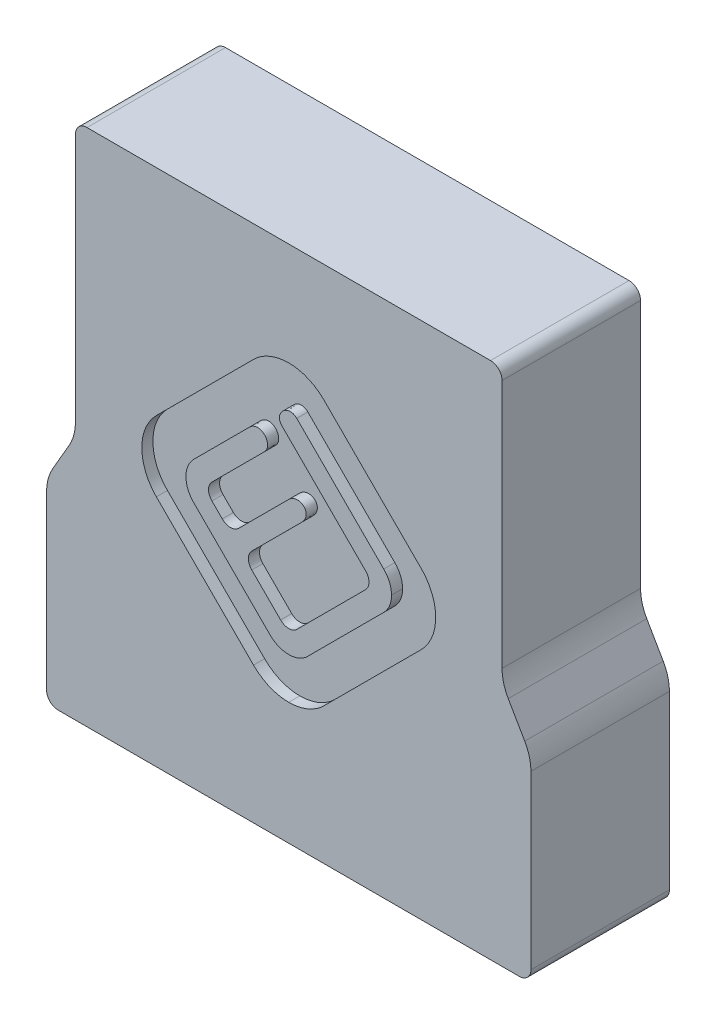
from build123d import *

# Parameters (mm, degrees)
OVERLAP_PROFILE_DEPTH              = 5.08
END_THICKNESS_DEPTH                = 13.97
FILLET1_R                          = 1.5875
FILLET2_R                          = 1.5875
SKETCH7_W                          = 28.6385
SKETCH7_H                          = 5.588
BOTTOM_FILL_DEPTH                  = 19.05
LOGO_INLAY_CUTOUT_DEPTH            = 1.524
SIDE_TRANSITION_FILL_DEPTH         = 19.05
SKETCH8_W                          = 52.324
SKETCH8_H                          = 20.828
MAGNETIC_CATCH_CUTOUT_DEPTH        = 7.62
FILLET3_R                          = 6.35
FILLET4_R                          = 6.35
SKETCH10_R                         = 3.175
ROUTER_BIT_RELIEF_DEPTH            = 7.62
FILLET5_R                          = 3.175
LOGO_FILL_FOR_1_8_ROUTER_BIT_DEPTH = 1.524


with BuildPart() as part:
    # Sketch1 → Overlap Profile (new body)
    with BuildSketch(Plane.XY):
        Polygon((-14.31925, -36.449), (14.31925, -36.449), (14.31925, -42.037), (33.30575, -42.037), (33.30575, -15.113), (29.337, -15.113), (29.337, 29.337), (-29.337, 29.337), (-29.337, -15.113), (-33.30575, -15.113), (-33.30575, -42.037), (-14.31925, -42.037), align=None)
        Polygon((-17.49425, -33.274), (17.49425, -33.274), (17.49425, -38.862), (30.13075, -38.862), (30.13075, -18.288), (26.162, -18.288), (26.162, 26.162), (-26.162, 26.162), (-26.162, -18.288), (-30.13075, -18.288), (-30.13075, -38.862), (-17.49425, -38.862), align=None, mode=Mode.SUBTRACT)
    extrude(amount=-OVERLAP_PROFILE_DEPTH)

    # Sketch2 → End Thickness (add)
    with BuildSketch(Plane.XY):
        Polygon((-29.337, 29.337), (-29.337, -15.113), (-33.30575, -15.113), (-33.30575, -42.037), (-14.31925, -42.037), (-14.31925, -36.449), (14.31925, -36.449), (14.31925, -42.037), (33.30575, -42.037), (33.30575, -15.113), (29.337, -15.113), (29.337, 29.337), align=None)
    extrude(amount=END_THICKNESS_DEPTH)

    # Fillet1
    fillet1_edges = [part.edges().sort_by_distance(p)[0] for p in [
        (17.49425, -38.862, -2.54),
        (17.49425, -33.274, -2.54),
        (-17.49425, -33.274, -2.54),
        (-17.49425, -38.862, -2.54),
        (-30.13075, -38.862, -2.54),
        (-30.13075, -18.288, -2.54),
        (-26.162, -18.288, -2.54),
        (-26.162, 26.162, -2.54),
        (26.162, 26.162, -2.54),
        (26.162, -18.288, -2.54),
        (30.13075, -18.288, -2.54),
        (30.13075, -38.862, -2.54),
    ]]
    fillet(fillet1_edges, radius=FILLET1_R)

    # Fillet2
    fillet2_edges = [part.edges().sort_by_distance(p)[0] for p in [
        (-33.30575, -42.037, 4.445),
        (-29.337, 29.337, 4.445),
        (29.337, 29.337, 4.445),
        (33.30575, -42.037, 4.445),
    ]]
    fillet(fillet2_edges, radius=FILLET2_R)

    # Sketch7 → Bottom Fill (add)
    with BuildSketch(Plane(origin=(0, 0, -5.08), x_dir=(-1, 0, 0), z_dir=(0, 0, -1))):
        with Locations((0, -39.243)):
            Rectangle(SKETCH7_W, SKETCH7_H)
    extrude(amount=-BOTTOM_FILL_DEPTH)

    # Sketch5 → Logo Inlay Cutout (cut)
    with BuildSketch(Plane.XY.offset(13.97)):
        with BuildLine():
            Line((18.205177148, -0.187852502), (4.843750234, 13.173642935))
            add(Edge.make_bspline(
                [(4.843750234, 13.173642935), (3.54948877, 14.467561785), (1.829288652, 15.180131934), (0, 15.180131934)],
                knots=[1, 1, 1, 1, 2, 2, 2, 2], degree=3))
            add(Edge.make_bspline(
                [(0, 15.180131934), (-1.829494221, 15.180131934), (-3.549865646, 14.467561785), (-4.843167789, 13.173642935)],
                knots=[2, 2, 2, 2, 3, 3, 3, 3], degree=3))
            Line((-4.843167789, 13.173642935), (-18.205279933, -0.187852502))
            add(Edge.make_bspline(
                [(-18.205279933, -0.187852502), (-20.875413695, -2.858740017), (-20.875413695, -7.203951534), (-18.204868795, -9.874907572)],
                knots=[4, 4, 4, 4, 5, 5, 5, 5], degree=3))
            Line((-18.204868795, -9.874907572), (-4.843167789, -23.236471532))
            add(Edge.make_bspline(
                [(-4.843167789, -23.236471532), (-3.549865646, -24.530321859), (-1.829494221, -25.242892008), (0, -25.242892008)],
                knots=[6, 6, 6, 6, 7, 7, 7, 7], degree=3))
            add(Edge.make_bspline(
                [(0, -25.242892008), (1.829288652, -25.242892008), (3.54948877, -24.530321859), (4.843750234, -23.236471532)],
                knots=[7, 7, 7, 7, 8, 8, 8, 8], degree=3))
            Line((4.843750234, -23.236471532), (18.205177148, -9.874907572))
            add(Edge.make_bspline(
                [(18.205177148, -9.874907572), (20.876475801, -7.203951534), (20.876475801, -2.858740017), (18.205177148, -0.187852502)],
                knots=[9, 9, 9, 9, 10, 10, 10, 10], degree=3))
        make_face()
        with BuildLine():
            Line((13.064585498, -8.006012655), (2.584548599, -18.487145921))
            add(Edge.make_bspline(
                [(2.584548599, -18.487145921), (1.895207729, -19.177583158), (0.977274302, -19.558570755), (0, -19.557474388)],
                knots=[1, 1, 1, 1, 2, 2, 2, 2], degree=3))
            add(Edge.make_bspline(
                [(0, -19.557474388), (-0.976691857, -19.557474388), (-1.893254825, -19.177583158), (-2.584411553, -18.485501371)],
                knots=[2, 2, 2, 2, 3, 3, 3, 3], degree=3))
            Line((-2.584411553, -18.485501371), (-13.06461976, -8.006012655))
            add(Edge.make_bspline(
                [(-13.06461976, -8.006012655), (-13.756016317, -7.315986556), (-14.136010332, -6.398601312), (-14.136010332, -5.421738148)],
                knots=[4, 4, 4, 4, 5, 5, 5, 5], degree=3))
            add(Edge.make_bspline(
                [(-14.136010332, -5.421738148), (-14.136010332, -4.444737938), (-13.755570918, -3.527798093), (-13.06461976, -2.837292334)],
                knots=[5, 5, 5, 5, 6, 6, 6, 6], degree=3))
            add(Edge.make_bspline(
                [(-13.06461976, -2.837292334), (-8.199798718, 2.027700015), (-5.428662129, 4.798768081)],
                knots=[6, 6, 6, 7, 7, 7], degree=2))
            add(Edge.make_bspline(
                [(-5.428662129, 4.798768081), (-3.839306583, 6.387198567), (-2.073024783, 4.195971697), (-3.333264603, 2.936382845)],
                knots=[7, 7, 7, 7, 8, 8, 8, 8], degree=3))
            add(Edge.make_bspline(
                [(-3.333264603, 2.936382845), (-6.104161362, 0.163773012), (-11.086122385, -4.81630363)],
                knots=[8, 8, 8, 9, 9, 9], degree=2))
            add(Edge.make_bspline(
                [(-11.086122385, -4.81630363), (-11.247288362, -4.978428928), (-11.336745072, -5.192871498), (-11.336745072, -5.421738148)],
                knots=[9, 9, 9, 9, 10, 10, 10, 10], degree=3))
            add(Edge.make_bspline(
                [(-11.336745072, -5.421738148), (-11.336059843, -5.650056615), (-11.247288362, -5.865150152), (-11.084991757, -6.026932835)],
                knots=[10, 10, 10, 10, 11, 11, 11, 11], degree=3))
            Line((-11.084991757, -6.026932835), (-8.017356366, -9.096898006))
            add(Edge.make_bspline(
                [(-8.017356366, -9.096898006), (-1.827952455, -2.908933077), (-0.025250707, -1.106128545)],
                knots=[12, 12, 12, 13, 13, 13], degree=2))
            add(Edge.make_bspline(
                [(-0.025250707, -1.106128545), (1.428977583, 0.347551562), (3.4298477, -1.263697066), (1.800783105, -2.893549675)],
                knots=[13, 13, 13, 13, 14, 14, 14, 14], degree=3))
            add(Edge.make_bspline(
                [(1.800783105, -2.893549675), (0.095383945, -4.599394234), (-6.209412612, -10.903299994)],
                knots=[14, 14, 14, 15, 15, 15], degree=2))
            Line((-6.209412612, -10.903299994), (-0.605503041, -16.507449395))
            add(Edge.make_bspline(
                [(-0.605503041, -16.507449395), (-0.443686096, -16.669095033), (-0.228352728, -16.758380436), (0, -16.758380436)],
                knots=[16, 16, 16, 16, 17, 17, 17, 17], degree=3))
            add(Edge.make_bspline(
                [(0, -16.758380436), (0.22955188, -16.758380436), (0.443754619, -16.669780262), (0.606016963, -16.50779201)],
                knots=[17, 17, 17, 17, 18, 18, 18, 18], degree=3))
            Line((0.606016963, -16.50779201), (11.086465, -6.027206927))
            add(Edge.make_bspline(
                [(11.086465, -6.027206927), (11.247630977, -5.865150152), (11.336436719, -5.649371385), (11.336847856, -5.422560423)],
                knots=[19, 19, 19, 19, 20, 20, 20, 20], degree=3))
            add(Edge.make_bspline(
                [(11.336847856, -5.422560423), (11.336847856, -5.192871498), (11.247630977, -4.977675175), (11.085779771, -4.81630363)],
                knots=[20, 20, 20, 20, 21, 21, 21, 21], degree=3))
            add(Edge.make_bspline(
                [(11.085779771, -4.81630363), (2.592908398, 3.67581399), (-0.913993358, 7.184051944)],
                knots=[21, 21, 21, 22, 22, 22], degree=2))
            add(Edge.make_bspline(
                [(-0.913993358, 7.184051944), (-2.11687947, 8.385807427), (-0.0785273, 10.307533538), (1.103356528, 9.124621866)],
                knots=[22, 22, 22, 22, 23, 23, 23, 23], degree=3))
            add(Edge.make_bspline(
                [(1.103356528, 9.124621866), (4.669701943, 5.557831051), (13.064585498, -2.837292334)],
                knots=[23, 23, 23, 24, 24, 24], degree=2))
            add(Edge.make_bspline(
                [(13.064585498, -2.837292334), (13.756393193, -3.527386955), (14.136147378, -4.444737938), (14.136147378, -5.42132701)],
                knots=[24, 24, 24, 24, 25, 25, 25, 25], degree=3))
            add(Edge.make_bspline(
                [(14.136147378, -5.42132701), (14.136147378, -6.397436422), (13.756393193, -7.315986556), (13.064585498, -8.006012655)],
                knots=[25, 25, 25, 25, 26, 26, 26, 26], degree=3))
        make_face(mode=Mode.SUBTRACT)
    extrude(amount=-LOGO_INLAY_CUTOUT_DEPTH, mode=Mode.SUBTRACT)

    # Sketch9 → Side Transition Fill (add)
    with BuildSketch(Plane.XY.offset(13.97)):
        Polygon((-33.30575, -15.113), (-29.337, -8.238923357), (-29.337, -15.113), align=None)
        Polygon((29.337, -15.113), (33.30575, -15.113), (29.337, -8.238923357), align=None)
    extrude(amount=-SIDE_TRANSITION_FILL_DEPTH)

    # Sketch8 → Magnetic Catch Cutout (cut)
    with BuildSketch(Plane(origin=(0, 0, 0), x_dir=(-1, 0, 0), z_dir=(0, 0, -1))):
        with Locations((0, -12.5095)):
            Rectangle(SKETCH8_W, SKETCH8_H)
    extrude(amount=-MAGNETIC_CATCH_CUTOUT_DEPTH, mode=Mode.SUBTRACT)

    # Fillet3
    fillet3_edges = [part.edges().sort_by_distance(p)[0] for p in [
        (-29.337, -8.238923357, 4.445),
        (29.337, -8.238923357, 4.445),
    ]]
    fillet(fillet3_edges, radius=FILLET3_R)

    # Fillet4
    fillet4_edges = [part.edges().sort_by_distance(p)[0] for p in [
        (-33.30575, -15.113, 4.445),
        (33.30575, -15.113, 4.445),
    ]]
    fillet(fillet4_edges, radius=FILLET4_R)

    # Sketch10 → Router Bit Relief (cut)
    with BuildSketch(Plane(origin=(0, 0, 0), x_dir=(-1, 0, 0), z_dir=(0, 0, -1))):
        with Locations((-22.987, -2.0955)):
            Circle(SKETCH10_R)
        with Locations((-22.987, -22.9235)):
            Circle(SKETCH10_R)
        with Locations((22.987, -22.9235)):
            Circle(SKETCH10_R)
        with Locations((22.987, -2.0955)):
            Circle(SKETCH10_R)
    extrude(amount=-ROUTER_BIT_RELIEF_DEPTH, mode=Mode.SUBTRACT)

    # Fillet5
    fillet5_edges = [part.edges().sort_by_distance(p)[0] for p in [
        (-19.812, -2.0955, 3.81),
        (-19.812, -22.9235, 3.81),
        (19.812, -22.9235, 3.81),
        (19.812, -2.0955, 3.81),
    ]]
    fillet(fillet5_edges, radius=FILLET5_R)

    # Sketch15 → Logo Fill for 1/8" Router Bit (add)
    with BuildSketch(Plane.XY.offset(13.97)):
        with BuildLine():
            Line((1.122975297, -15.990826916), (0.606016963, -16.50779201))
            add(Edge.make_bspline(
                [(0.606016963, -16.50779201), (0.443754619, -16.669780262), (0.22955188, -16.758380436), (0, -16.758380436)],
                knots=[17, 17, 17, 17, 18, 18, 18, 18], degree=3))
            add(Edge.make_bspline(
                [(0, -16.758380436), (-0.228352728, -16.758380436), (-0.443686096, -16.669095033), (-0.605503041, -16.507449395)],
                knots=[16, 16, 16, 16, 17, 17, 17, 17], degree=3))
            Line((-0.605503041, -16.507449395), (-1.122120092, -15.990810235))
            ThreePointArc((-1.122120092, -15.990810235), (0.000424148, -16.45580224), (1.122975297, -15.990826916))
        make_face()
        with BuildLine():
            Line((-5.086852244, -12.025908404), (-6.209412612, -10.903299994))
            add(Edge.make_bspline(
                [(-6.209412612, -10.903299994), (-5.628564976, -10.322534425), (-5.086754951, -9.780795126)],
                knots=[14, 14, 14, 14.092127895, 14.092127895, 14.092127895], degree=2))
            ThreePointArc((-5.086754951, -9.780795126), (-5.551796207, -10.903331614), (-5.086852244, -12.025908404))
        make_face()
        with BuildLine():
            Line((-10.568867647, -6.543448927), (-11.084991757, -6.026932835))
            add(Edge.make_bspline(
                [(-11.084991757, -6.026932835), (-11.247288362, -5.865150152), (-11.336059843, -5.650056615), (-11.336745072, -5.421738148)],
                knots=[10, 10, 10, 10, 11, 11, 11, 11], degree=3))
            add(Edge.make_bspline(
                [(-11.336745072, -5.421738148), (-11.336745072, -5.192871498), (-11.247288362, -4.978428928), (-11.086122385, -4.81630363)],
                knots=[9, 9, 9, 9, 10, 10, 10, 10], degree=3))
            add(Edge.make_bspline(
                [(-11.086122385, -4.81630363), (-10.824126761, -4.554407103), (-10.568246029, -4.29861552)],
                knots=[8, 8, 8, 8.052588855, 8.052588855, 8.052588855], degree=2))
            ThreePointArc((-10.568246029, -4.29861552), (-11.033409548, -5.420903501), (-10.568867647, -6.543448927))
        make_face()
        with BuildLine():
            Line((11.086465, -6.027206927), (10.569030585, -6.544648108))
            ThreePointArc((10.569030585, -6.544648108), (11.03399123, -5.422085425), (10.568976834, -4.299545007))
            add(Edge.make_bspline(
                [(10.568976834, -4.299545007), (10.825028323, -4.555575325), (11.085779771, -4.81630363)],
                knots=[21.96929761, 21.96929761, 21.96929761, 22, 22, 22], degree=2))
            add(Edge.make_bspline(
                [(11.085779771, -4.81630363), (11.247630977, -4.977675175), (11.336847856, -5.192871498), (11.336847856, -5.422560423)],
                knots=[20, 20, 20, 20, 21, 21, 21, 21], degree=3))
            add(Edge.make_bspline(
                [(11.336847856, -5.422560423), (11.336436719, -5.649371385), (11.247630977, -5.865150152), (11.086465, -6.027206927)],
                knots=[19, 19, 19, 19, 20, 20, 20, 20], degree=3))
        make_face()
        with BuildLine():
            Line((-8.017356366, -9.096898006), (-9.139760019, -7.97364192))
            ThreePointArc((-9.139760019, -7.97364192), (-8.017192198, -8.439036041), (-6.89439572, -7.974193843))
            add(Edge.make_bspline(
                [(-6.89439572, -7.974193843), (-7.436562853, -8.516239522), (-8.017356366, -9.096898006)],
                knots=[12.906163256, 12.906163256, 12.906163256, 13, 13, 13], degree=2))
        make_face()
    extrude(amount=-LOGO_FILL_FOR_1_8_ROUTER_BIT_DEPTH)


solid = part.part
